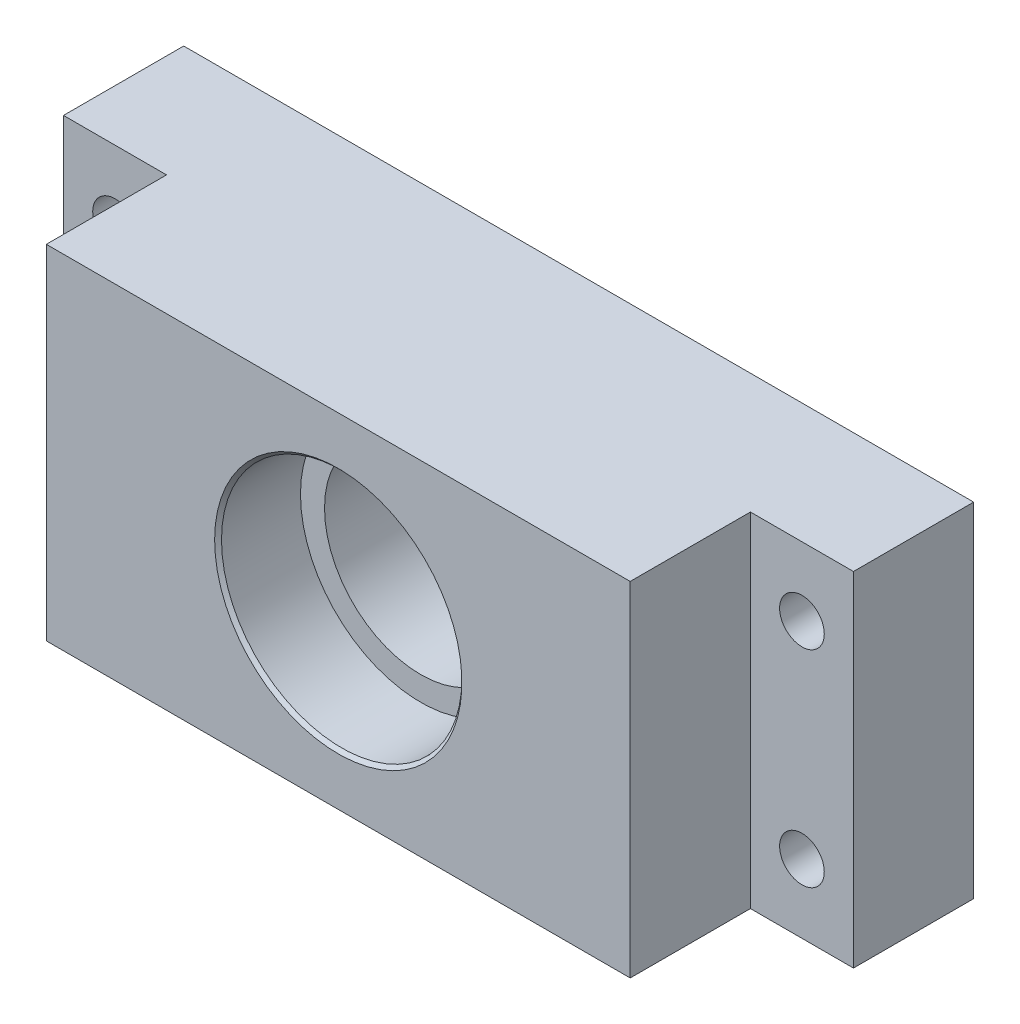
from build123d import *

# Parameters (mm, degrees)
SZKIC1_W                    = 115
SZKIC1_H                    = 50
SZKIC1_R                    = 14
DODANIE_WYCI_GNI_CIE1_DEPTH = 35
SZKIC2_R                    = 17.5
WYTNIJ_WYCI_GNI_CIE1_DEPTH  = 12
SZKIC3_R                    = 17.5
WYTNIJ_WYCI_GNI_CIE2_DEPTH  = 12
SZKIC4_R                    = 3.25
WYTNIJ_WYCI_GNI_CIE3_DEPTH  = 36
SZKIC5_W                    = 15
SZKIC5_H                    = 50
WYTNIJ_WYCI_GNI_CIE4_DEPTH  = 17.5
SFAZOWANIE1_SIZE            = 0.5


with BuildPart() as part:
    # Szkic1 → Dodanie-wyciągnięcie1 (new body)
    with BuildSketch(Plane.XY):
        Rectangle(SZKIC1_W, SZKIC1_H)
        Circle(SZKIC1_R, mode=Mode.SUBTRACT)
    extrude(amount=DODANIE_WYCI_GNI_CIE1_DEPTH)

    # Szkic2 → Wytnij-wyciągnięcie1 (cut)
    with BuildSketch(Plane.XY.offset(35)):
        Circle(SZKIC2_R)
    extrude(amount=-WYTNIJ_WYCI_GNI_CIE1_DEPTH, mode=Mode.SUBTRACT)

    # Szkic3 → Wytnij-wyciągnięcie2 (cut)
    with BuildSketch(Plane(origin=(0, 0, 0), x_dir=(-1, 0, 0), z_dir=(0, 0, -1))):
        Circle(SZKIC3_R)
    extrude(amount=-WYTNIJ_WYCI_GNI_CIE2_DEPTH, mode=Mode.SUBTRACT)

    # Szkic4 → Wytnij-wyciągnięcie3 (cut, through all)
    with BuildSketch(Plane(origin=(0, 0, 0), x_dir=(-1, 0, 0), z_dir=(0, 0, -1))):
        with Locations((-50, 15)):
            Circle(SZKIC4_R)
        with Locations((-50, -15)):
            Circle(SZKIC4_R)
        with Locations((50, 15)):
            Circle(SZKIC4_R)
        with Locations((50, -15)):
            Circle(SZKIC4_R)
    extrude(amount=-WYTNIJ_WYCI_GNI_CIE3_DEPTH, mode=Mode.SUBTRACT)

    # Szkic5 → Wytnij-wyciągnięcie4 (cut)
    with BuildSketch(Plane.XY.offset(35)):
        with Locations((50, 0)):
            Rectangle(SZKIC5_W, SZKIC5_H)
        with Locations((-50, 0)):
            Rectangle(SZKIC5_W, SZKIC5_H)
    extrude(amount=-WYTNIJ_WYCI_GNI_CIE4_DEPTH, mode=Mode.SUBTRACT)

    # Sfazowanie1
    sfazowanie1_edges = [part.edges().sort_by_distance(p)[0] for p in [
        (-17.5, 0, 35),
        (17.5, 0, 0),
    ]]
    chamfer(sfazowanie1_edges, length=SFAZOWANIE1_SIZE)


solid = part.part
